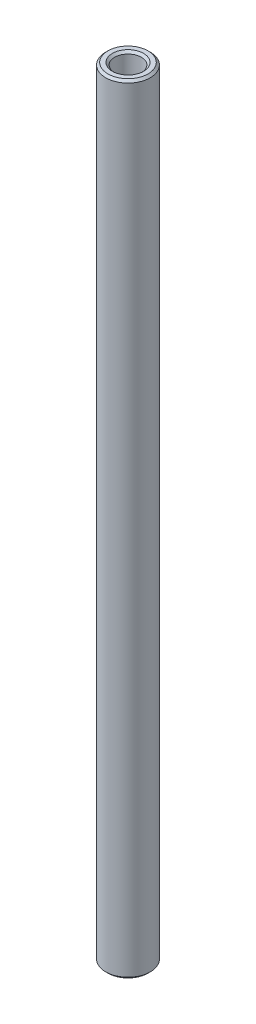
from build123d import *

# Parameters (mm, degrees)
SKETCH1_R           = 10
BOSS_EXTRUDE1_DEPTH = 175
CHAMFER2_SIZE       = 0.5
SKETCH2_R           = 3
CUT_EXTRUDE1_DEPTH  = 20
CHAMFER3_SIZE       = 0.5
SKETCH3_R           = 3
CUT_EXTRUDE2_DEPTH  = 20
SKETCH4_R           = 10
SKETCH4_R_2         = 5
CUT_EXTRUDE3_DEPTH  = 273
CHAMFER5_SIZE       = 0.5


with BuildPart() as part:
    # Sketch1 → Boss-Extrude1 (new body)
    with BuildSketch(Plane(origin=(0, 0, 0), x_dir=(1, 0, 0), z_dir=(0, 1, 0))):
        Circle(SKETCH1_R)
    extrude(amount=BOSS_EXTRUDE1_DEPTH)

    # Chamfer2
    chamfer2_edges = [part.edges().sort_by_distance(p)[0] for p in [
        (-10, 0, 0),
        (-10, 175, 0),
    ]]
    chamfer(chamfer2_edges, length=CHAMFER2_SIZE)

    # Sketch2 → Cut-Extrude1 (cut)
    with BuildSketch(Plane(origin=(0, 175, 0), x_dir=(1, 0, 0), z_dir=(0, 1, 0))):
        Circle(SKETCH2_R)
    extrude(amount=-CUT_EXTRUDE1_DEPTH, mode=Mode.SUBTRACT)

    # Chamfer3
    chamfer3_edges = [part.edges().sort_by_distance(p)[0] for p in [
        (-3, 175, 0),
    ]]
    chamfer(chamfer3_edges, length=CHAMFER3_SIZE)

    # Sketch3 → Cut-Extrude2 (cut)
    with BuildSketch(Plane.XZ):
        Circle(SKETCH3_R)
    extrude(amount=-CUT_EXTRUDE2_DEPTH, mode=Mode.SUBTRACT)

    # Sketch4 → Cut-Extrude3 (cut)
    with BuildSketch(Plane.XZ):
        Circle(SKETCH4_R)
        Circle(SKETCH4_R_2, mode=Mode.SUBTRACT)
    extrude(amount=-CUT_EXTRUDE3_DEPTH, mode=Mode.SUBTRACT)

    # Chamfer5
    chamfer5_edges = [part.edges().sort_by_distance(p)[0] for p in [
        (-3, 0, 0),
        (-5, 175, 0),
        (-5, 0, 0),
    ]]
    chamfer(chamfer5_edges, length=CHAMFER5_SIZE)


solid = part.part
